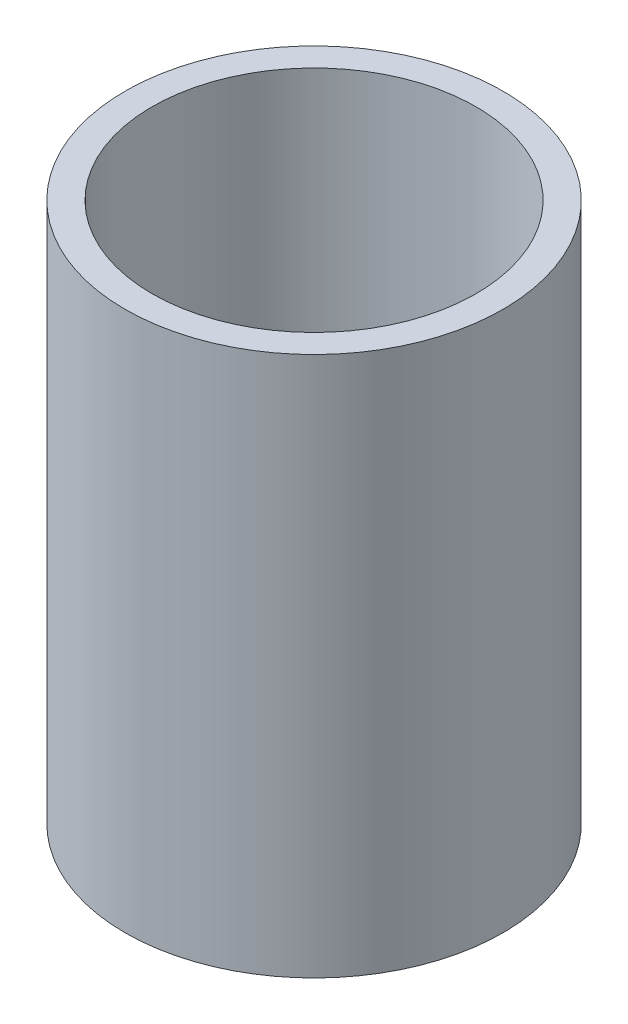
from build123d import *

# Parameters (mm, degrees)
SKETCH_2_W = 2.5
SKETCH_2_H = 50


with BuildPart() as part:
    # 草图2 → 旋转1 (revolve)
    with BuildSketch(Plane.XY):
        with Locations((16.25, -25)):
            Rectangle(SKETCH_2_W, SKETCH_2_H)
    revolve(axis=Axis((0, 0, 0), (0, -1, 0)))


solid = part.part
